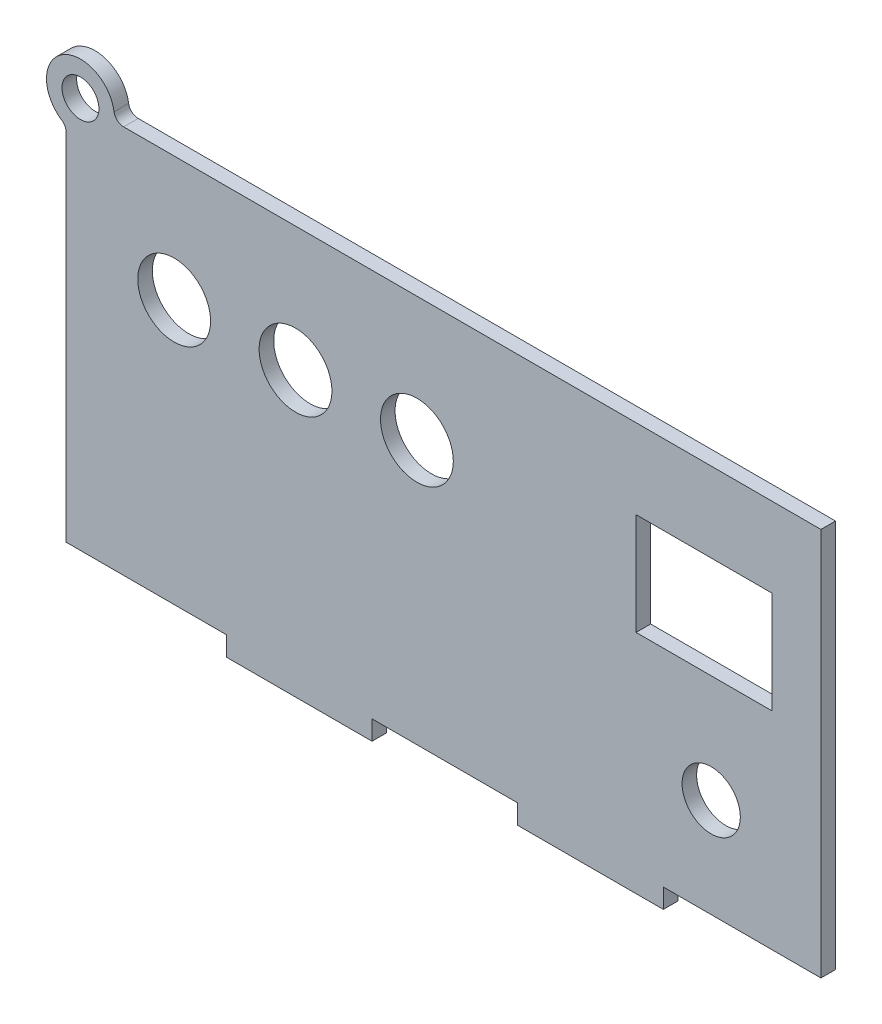
from build123d import *

# Parameters (mm, degrees)
SKETCH1_R           = 3.8
SKETCH1_R_2         = 7.5
SKETCH1_R_3         = 6
SKETCH1_W           = 28
SKETCH1_H           = 21
BOSS_EXTRUDE1_DEPTH = 3


with BuildPart() as part:
    # Sketch1 → Boss-Extrude1 (new body)
    with BuildSketch(Plane.XY):
        with BuildLine():
            Line((-44.907534458, -41.831082964), (-44.907534458, -37.831082964))
            Line((-44.907534458, -37.831082964), (-74.907534458, -37.831082964))
            Line((-74.907534458, -37.831082964), (-77.907534458, -37.831082964))
            Line((-77.907534458, -37.831082964), (-77.907534458, 35.317270492))
            ThreePointArc((-77.907534458, 35.317270492), (-78.146852772, 36.26595379), (-78.807534458, 36.987599801))
            ThreePointArc((-78.807534458, 36.987599801), (-78.73201274, 48.728946501), (-68.036732481, 43.883752382))
            ThreePointArc((-68.036732481, 43.883752382), (-67.363200969, 42.667177293), (-66.059360488, 42.183752382))
            Line((-66.059360488, 42.183752382), (77.553779546, 42.183752382))
            Line((77.553779546, 42.183752382), (77.553779546, -37.831082964))
            Line((77.553779546, -37.831082964), (45.092465542, -37.831082964))
            Line((45.092465542, -37.831082964), (45.092465542, -41.831082964))
            Line((45.092465542, -41.831082964), (15.092465542, -41.831082964))
            Line((15.092465542, -41.831082964), (15.092465542, -37.831082964))
            Line((15.092465542, -37.831082964), (-14.907534458, -37.831082964))
            Line((-14.907534458, -37.831082964), (-14.907534458, -41.831082964))
            Line((-14.907534458, -41.831082964), (-44.907534458, -41.831082964))
        make_face()
        with Locations((-74.957534458, 42.833752382)):
            Circle(SKETCH1_R, mode=Mode.SUBTRACT)
        with Locations((-55.663947073, 16.489262872)):
            Circle(SKETCH1_R_2, mode=Mode.SUBTRACT)
        with Locations((-30.663947073, 16.489262872)):
            Circle(SKETCH1_R_2, mode=Mode.SUBTRACT)
        with Locations((-5.663947073, 16.489262872)):
            Circle(SKETCH1_R_2, mode=Mode.SUBTRACT)
        with Locations((54.950876551, -17.44070313)):
            Circle(SKETCH1_R_3, mode=Mode.SUBTRACT)
        with Locations((53.477773965, 15.276803872)):
            Rectangle(SKETCH1_W, SKETCH1_H, mode=Mode.SUBTRACT)
    extrude(amount=BOSS_EXTRUDE1_DEPTH)


solid = part.part
